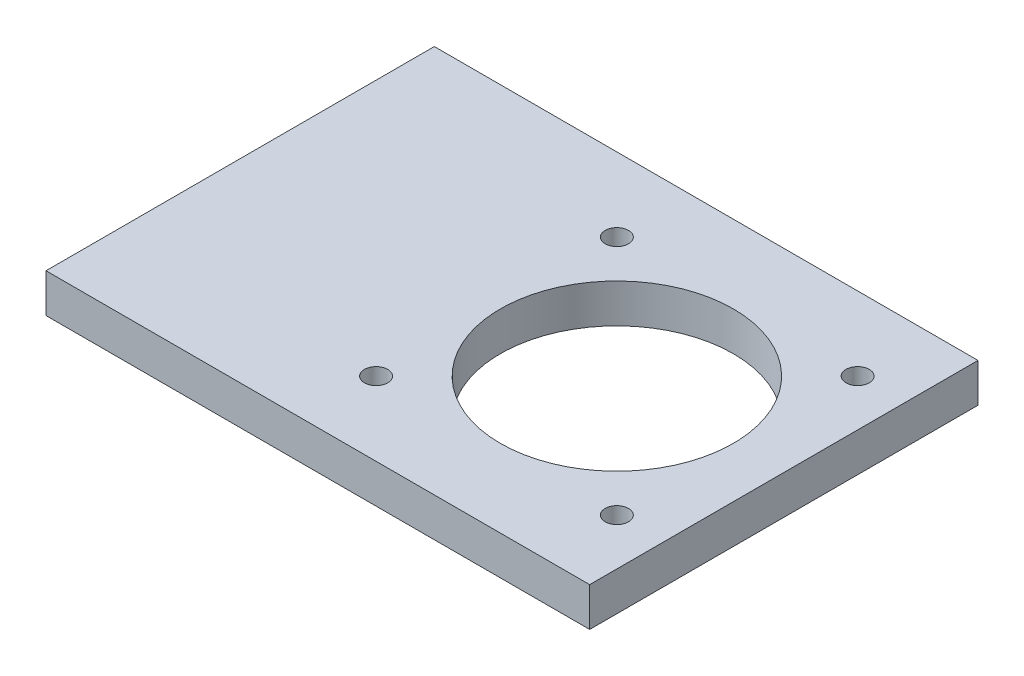
from build123d import *

# Parameters (mm, degrees)
SKETCH1_W           = 70
SKETCH1_H           = 50
BOSS_EXTRUDE1_DEPTH = 5
SKETCH2_R           = 1.5
CUT_EXTRUDE1_DEPTH  = 5
SKETCH3_R           = 15
CUT_EXTRUDE2_DEPTH  = 5


with BuildPart() as part:
    # Sketch1 → Boss-Extrude1 (new body)
    with BuildSketch(Plane(origin=(0, 0, 0), x_dir=(1, 0, 0), z_dir=(0, 1, 0))):
        Rectangle(SKETCH1_W, SKETCH1_H)
    extrude(amount=BOSS_EXTRUDE1_DEPTH)

    # Sketch2 → Cut-Extrude1 (cut)
    with BuildSketch(Plane(origin=(0, 5, 0), x_dir=(1, 0, 0), z_dir=(0, 1, 0))):
        with Locations((29, 15.5)):
            Circle(SKETCH2_R)
        with Locations((-2, 15.5)):
            Circle(SKETCH2_R)
    cut_extrude1 = extrude(amount=-CUT_EXTRUDE1_DEPTH, mode=Mode.SUBTRACT)

    # Mirror1: Cut-Extrude1 across plane
    add(cut_extrude1.mirror(Plane.XY), mode=Mode.SUBTRACT)

    # Sketch3 → Cut-Extrude2 (cut)
    with BuildSketch(Plane(origin=(0, 5, 0), x_dir=(1, 0, 0), z_dir=(0, 1, 0))):
        with Locations((13.5, 0)):
            Circle(SKETCH3_R)
    extrude(amount=-CUT_EXTRUDE2_DEPTH, mode=Mode.SUBTRACT)


solid = part.part
